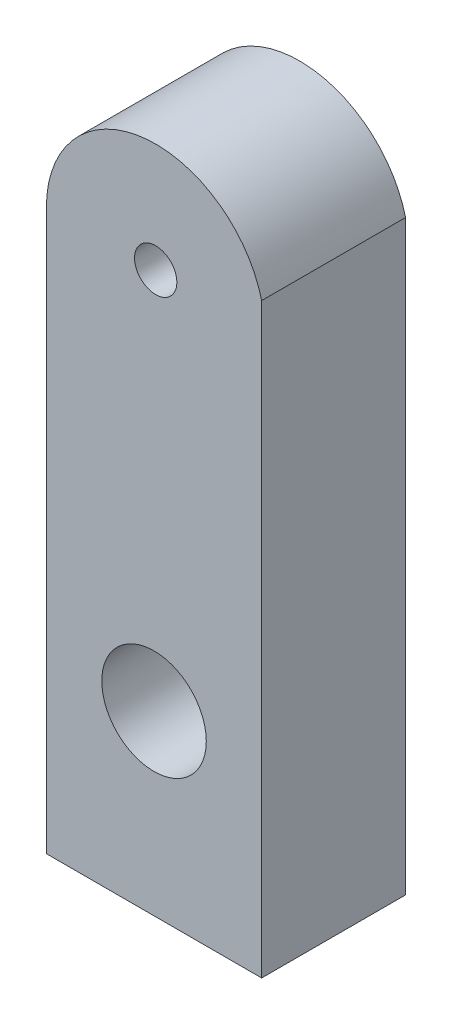
from build123d import *

# Parameters (mm, degrees)
SKETCH1_R           = 2.5
SKETCH1_R_2         = 6.171796323
BOSS_EXTRUDE1_DEPTH = 17


with BuildPart() as part:
    # Sketch1 → Boss-Extrude1 (new body)
    with BuildSketch(Plane.XY):
        with BuildLine():
            Line((-12.906979053, 0), (-12.906979053, -66.151858576))
            Line((-12.906979053, -66.151858576), (12.517811956, -66.151858576))
            Line((12.517811956, -66.151858576), (12.517811956, 3.145551163))
            ThreePointArc((12.517811956, 3.145551163), (-1.584766793, 12.8093178), (-12.906979053, 0))
        make_face()
        Circle(SKETCH1_R, mode=Mode.SUBTRACT)
        with Locations((-0.194583549, -45.214046835)):
            Circle(SKETCH1_R_2, mode=Mode.SUBTRACT)
    extrude(amount=BOSS_EXTRUDE1_DEPTH)


solid = part.part
